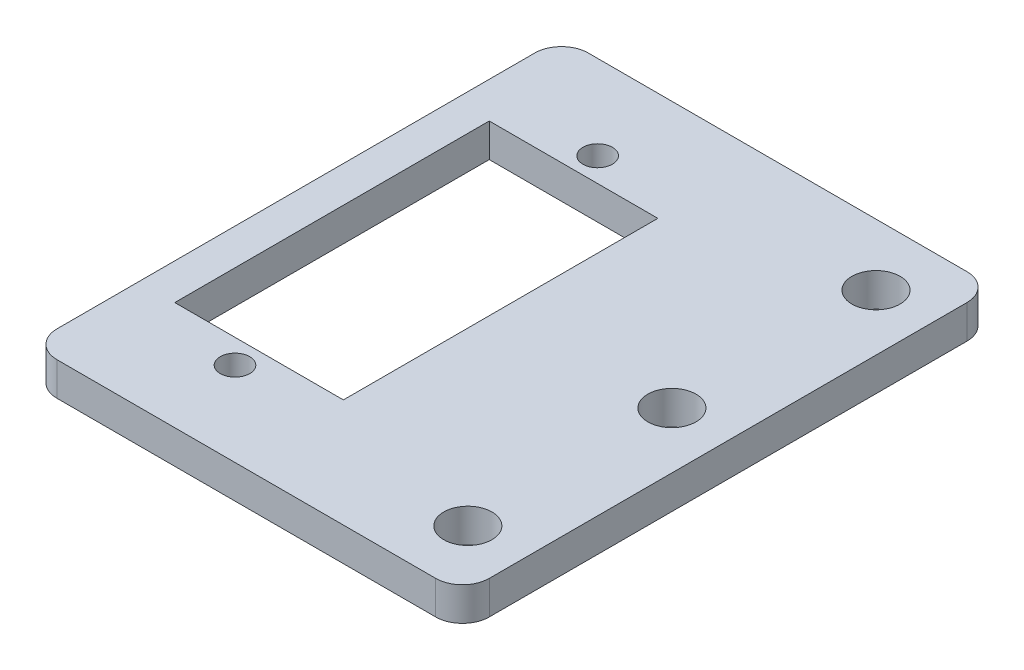
from build123d import *

# Parameters (mm, degrees)
SKETCH1_W             = 32.299999994
SKETCH1_H             = 39.7
PLATE_SIZE_DEPTH      = 2.5
SKETCH2_W             = 12.6
SKETCH2_H             = 23.5
SERVO_CLEARANCE_DEPTH = 3.5
M2_CLEARANCE_HOLE1_D  = 2.2
M3_CLEARANCE_HOLE1_D  = 3.6
CORNER_FILLET1_R      = 2


with BuildPart() as part:
    # Sketch1 → Plate Size (new body)
    with BuildSketch(Plane(origin=(0, 0, 0), x_dir=(1, 0, 0), z_dir=(0, 1, 0))):
        with Locations((7.149999997, 0)):
            Rectangle(SKETCH1_W, SKETCH1_H)
    extrude(amount=-PLATE_SIZE_DEPTH)

    # Sketch2 → Servo Clearance (cut, through all)
    with BuildSketch(Plane(origin=(0, 0, 0), x_dir=(1, 0, 0), z_dir=(0, 1, 0))):
        Rectangle(SKETCH2_W, SKETCH2_H)
    extrude(amount=-SERVO_CLEARANCE_DEPTH, mode=Mode.SUBTRACT)

    # M2 Clearance Hole1 (through all)
    with Locations(Plane(origin=(0, 0, 0), x_dir=(1, 0, 0), z_dir=(0, 1, 0))):
        with Locations((0, -13.55), (0, 13.55)):
            Hole(M2_CLEARANCE_HOLE1_D / 2)

    # M3 Clearance Hole1 (through all)
    with Locations(Plane(origin=(0, 0, 0), x_dir=(1, 0, 0), z_dir=(0, 1, 0))):
        with Locations((19.099999994, -15.25), (19.099999994, 0), (19.099999994, 15.25)):
            Hole(M3_CLEARANCE_HOLE1_D / 2)

    # Corner Fillet1
    corner_fillet1_edges = [part.edges().sort_by_distance(p)[0] for p in [
        (-9, -1.25, -19.85),
        (23.299999994, -1.25, -19.85),
        (23.299999994, -1.25, 19.85),
        (-9, -1.25, 19.85),
    ]]
    fillet(corner_fillet1_edges, radius=CORNER_FILLET1_R)


solid = part.part
